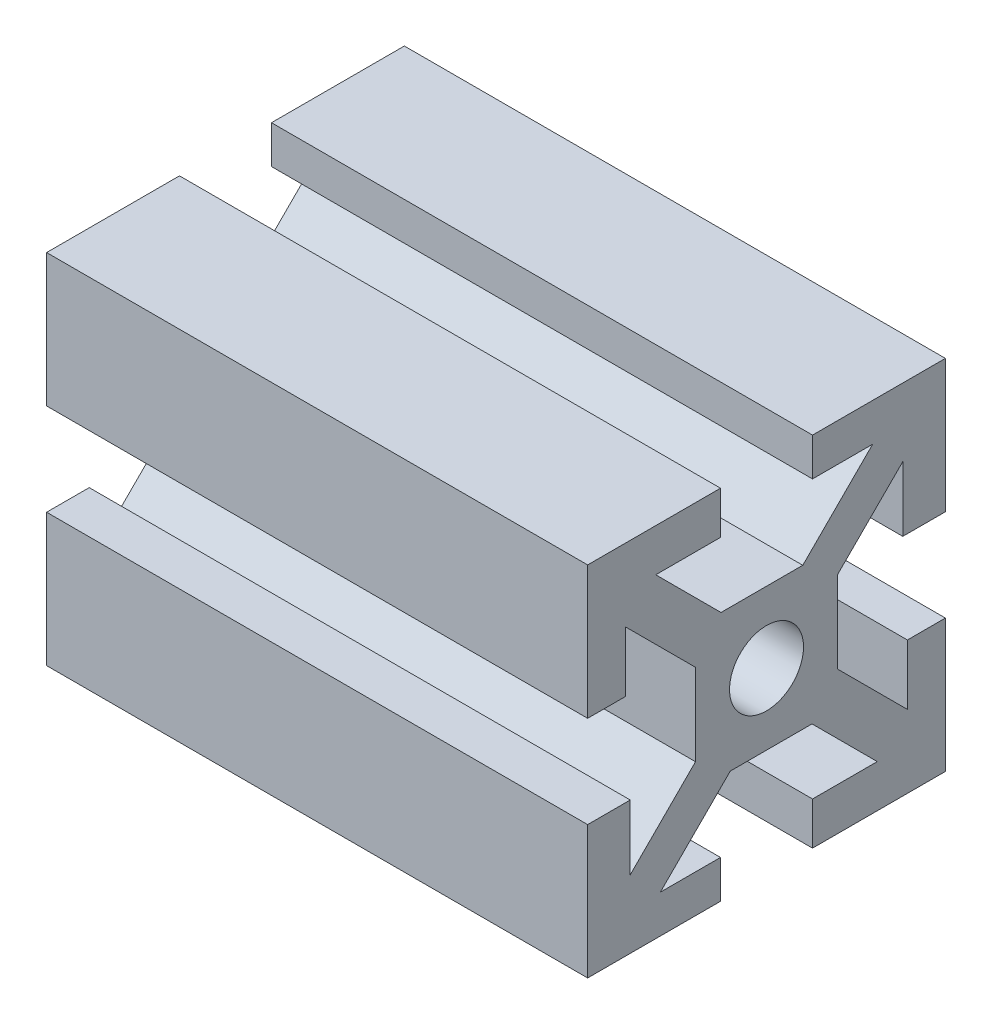
from build123d import *

# Parameters (mm, degrees)
SKETCH1_R           = 2.605
BOSS_EXTRUDE1_DEPTH = 38.1
CIRPATTERN1_COUNT   = 4


with BuildPart() as part:
    # Sketch1 → Boss-Extrude1 (new body)
    with BuildSketch(Plane(origin=(0, 0, 0), x_dir=(0, 0, -1), z_dir=(1, 0, 0))):
        Polygon((5, -5), (5, 3.203948776), (9.596194078, 7.800142853), (9.596194078, 3.24), (12.596194078, 3.24), (12.596194078, 12.596194078), (3.24, 12.596194078), (3.24, 9.921463197), (7.474873734, 9.921463197), (2.553410537, 5), (-5, 5), (-5, -5), align=None)
        Circle(SKETCH1_R, mode=Mode.SUBTRACT)
    boss_extrude1 = extrude(amount=BOSS_EXTRUDE1_DEPTH)

    # CirPattern1: Boss-Extrude1 ×4 about axis
    cirpattern1_axis = Axis((0, 0, 0), (1, 0, 0))
    for i in range(1, CIRPATTERN1_COUNT):
        add(boss_extrude1.rotate(cirpattern1_axis, i * 360 / CIRPATTERN1_COUNT))


solid = part.part
